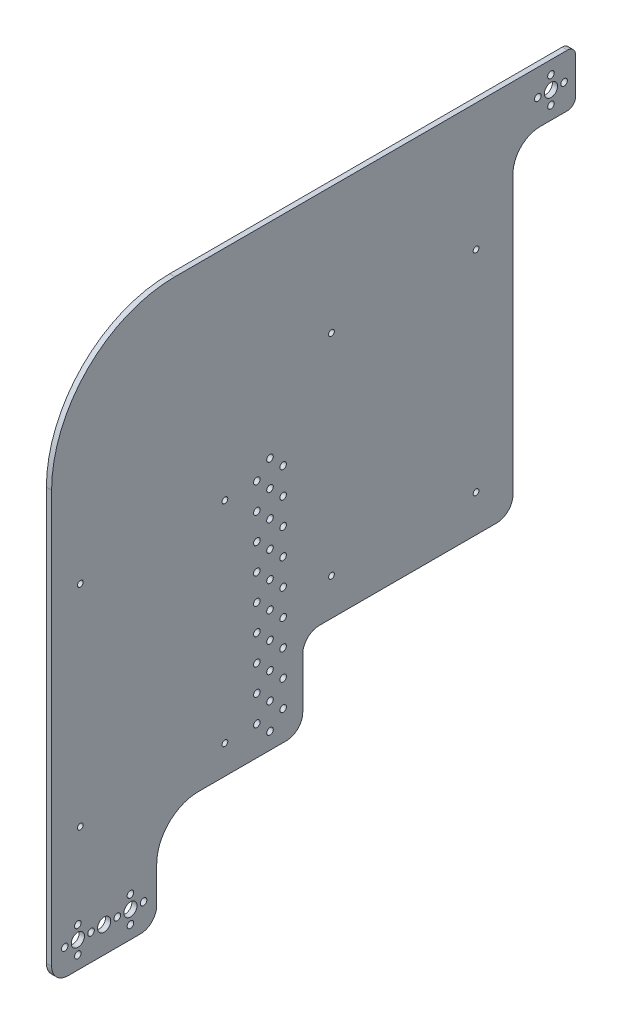
from build123d import *

# Parameters (mm, degrees)
SKETCH1_R           = 4
SKETCH1_R_2         = 2
SKETCH1_R_3         = 1.75
BOSS_EXTRUDE1_DEPTH = 3.175


with BuildPart() as part:
    # Sketch1 → Boss-Extrude1 (new body)
    with BuildSketch(Plane(origin=(0, 0, 0), x_dir=(0, 0, -1), z_dir=(1, 0, 0))):
        with BuildLine():
            Line((-240, -288), (-240, -310))
            ThreePointArc((-240, -310), (-242.928932188, -317.071067812), (-250, -320))
            Line((-250, -320), (-294, -320))
            ThreePointArc((-294, -320), (-301.071067812, -317.071067812), (-304, -310))
            Line((-304, -310), (-304, -288))
            Line((-304, -288), (-304, -59))
            ThreePointArc((-304, -59), (-282.033008589, -5.966991411), (-229, 16))
            Line((-229, 16), (-16, 16))
            Line((-16, 16), (10, 16))
            ThreePointArc((10, 16), (13.535533906, 14.535533906), (15, 11))
            Line((15, 11), (15, -11))
            ThreePointArc((15, -11), (13.535533906, -14.535533906), (10, -16))
            Line((10, -16), (-6.55, -16))
            ThreePointArc((-6.55, -16), (-18.252617229, -20.847382771), (-23.1, -32.55))
            Line((-23.1, -32.55), (-23.1, -201.8))
            ThreePointArc((-23.1, -201.8), (-26.028932188, -208.871067812), (-33.1, -211.8))
            Line((-33.1, -211.8), (-141.1, -211.8))
            ThreePointArc((-141.1, -211.8), (-148.171067812, -214.728932188), (-151.1, -221.8))
            Line((-151.1, -221.8), (-151.1, -252.6))
            ThreePointArc((-151.1, -252.6), (-154.028932188, -259.671067812), (-161.1, -262.6))
            Line((-161.1, -262.6), (-214.6, -262.6))
            ThreePointArc((-214.6, -262.6), (-232.560512242, -270.039487758), (-240, -288))
        make_face()
        with Locations((-256, -304)):
            Circle(SKETCH1_R, mode=Mode.SUBTRACT)
        Circle(SKETCH1_R, mode=Mode.SUBTRACT)
        with Locations((8, 0)):
            Circle(SKETCH1_R_2, mode=Mode.SUBTRACT)
        with Locations((0, -8)):
            Circle(SKETCH1_R_2, mode=Mode.SUBTRACT)
        with Locations((-8, 0)):
            Circle(SKETCH1_R_2, mode=Mode.SUBTRACT)
        with Locations((0, 8)):
            Circle(SKETCH1_R_2, mode=Mode.SUBTRACT)
        with Locations((-248, -304)):
            Circle(SKETCH1_R_2, mode=Mode.SUBTRACT)
        with Locations((-256, -312)):
            Circle(SKETCH1_R_2, mode=Mode.SUBTRACT)
        with Locations((-256, -296)):
            Circle(SKETCH1_R_2, mode=Mode.SUBTRACT)
        with Locations((-264, -304)):
            Circle(SKETCH1_R_2, mode=Mode.SUBTRACT)
        with Locations((-272, -304)):
            Circle(SKETCH1_R, mode=Mode.SUBTRACT)
        with Locations((-288, -312)):
            Circle(SKETCH1_R_2, mode=Mode.SUBTRACT)
        with Locations((-280, -304)):
            Circle(SKETCH1_R_2, mode=Mode.SUBTRACT)
        with Locations((-288, -296)):
            Circle(SKETCH1_R_2, mode=Mode.SUBTRACT)
        with Locations((-288, -304)):
            Circle(SKETCH1_R, mode=Mode.SUBTRACT)
        with Locations((-296, -304)):
            Circle(SKETCH1_R_2, mode=Mode.SUBTRACT)
        with Locations((-171.05, -252.6)):
            Circle(SKETCH1_R_2, mode=Mode.SUBTRACT)
        with Locations((-179.05, -244.6)):
            Circle(SKETCH1_R_2, mode=Mode.SUBTRACT)
        with Locations((-171.05, -236.6)):
            Circle(SKETCH1_R_2, mode=Mode.SUBTRACT)
        with Locations((-163.05, -244.6)):
            Circle(SKETCH1_R_2, mode=Mode.SUBTRACT)
        with Locations((-179.05, -228.6)):
            Circle(SKETCH1_R_2, mode=Mode.SUBTRACT)
        with Locations((-171.05, -220.6)):
            Circle(SKETCH1_R_2, mode=Mode.SUBTRACT)
        with Locations((-163.05, -228.6)):
            Circle(SKETCH1_R_2, mode=Mode.SUBTRACT)
        with Locations((-179.05, -212.6)):
            Circle(SKETCH1_R_2, mode=Mode.SUBTRACT)
        with Locations((-171.05, -204.6)):
            Circle(SKETCH1_R_2, mode=Mode.SUBTRACT)
        with Locations((-163.05, -212.6)):
            Circle(SKETCH1_R_2, mode=Mode.SUBTRACT)
        with Locations((-179.05, -196.6)):
            Circle(SKETCH1_R_2, mode=Mode.SUBTRACT)
        with Locations((-171.05, -188.6)):
            Circle(SKETCH1_R_2, mode=Mode.SUBTRACT)
        with Locations((-163.05, -196.6)):
            Circle(SKETCH1_R_2, mode=Mode.SUBTRACT)
        with Locations((-179.05, -180.6)):
            Circle(SKETCH1_R_2, mode=Mode.SUBTRACT)
        with Locations((-171.05, -172.6)):
            Circle(SKETCH1_R_2, mode=Mode.SUBTRACT)
        with Locations((-163.05, -180.6)):
            Circle(SKETCH1_R_2, mode=Mode.SUBTRACT)
        with Locations((-179.05, -164.6)):
            Circle(SKETCH1_R_2, mode=Mode.SUBTRACT)
        with Locations((-171.05, -156.6)):
            Circle(SKETCH1_R_2, mode=Mode.SUBTRACT)
        with Locations((-163.05, -164.6)):
            Circle(SKETCH1_R_2, mode=Mode.SUBTRACT)
        with Locations((-179.05, -148.6)):
            Circle(SKETCH1_R_2, mode=Mode.SUBTRACT)
        with Locations((-171.05, -140.6)):
            Circle(SKETCH1_R_2, mode=Mode.SUBTRACT)
        with Locations((-163.05, -148.6)):
            Circle(SKETCH1_R_2, mode=Mode.SUBTRACT)
        with Locations((-179.05, -132.6)):
            Circle(SKETCH1_R_2, mode=Mode.SUBTRACT)
        with Locations((-171.05, -124.6)):
            Circle(SKETCH1_R_2, mode=Mode.SUBTRACT)
        with Locations((-163.05, -132.6)):
            Circle(SKETCH1_R_2, mode=Mode.SUBTRACT)
        with Locations((-179.05, -116.6)):
            Circle(SKETCH1_R_2, mode=Mode.SUBTRACT)
        with Locations((-171.05, -108.6)):
            Circle(SKETCH1_R_2, mode=Mode.SUBTRACT)
        with Locations((-163.05, -116.6)):
            Circle(SKETCH1_R_2, mode=Mode.SUBTRACT)
        with Locations((-286.5, -117.1)):
            Circle(SKETCH1_R_3, mode=Mode.SUBTRACT)
        with Locations((-198.5, -117.1)):
            Circle(SKETCH1_R_3, mode=Mode.SUBTRACT)
        with Locations((-198.5, -245.1)):
            Circle(SKETCH1_R_3, mode=Mode.SUBTRACT)
        with Locations((-286.5, -245.1)):
            Circle(SKETCH1_R_3, mode=Mode.SUBTRACT)
        with Locations((-133.6, -61.3)):
            Circle(SKETCH1_R_3, mode=Mode.SUBTRACT)
        with Locations((-45.6, -61.3)):
            Circle(SKETCH1_R_3, mode=Mode.SUBTRACT)
        with Locations((-45.6, -189.3)):
            Circle(SKETCH1_R_3, mode=Mode.SUBTRACT)
        with Locations((-133.6, -189.3)):
            Circle(SKETCH1_R_3, mode=Mode.SUBTRACT)
    extrude(amount=-BOSS_EXTRUDE1_DEPTH)


solid = part.part
